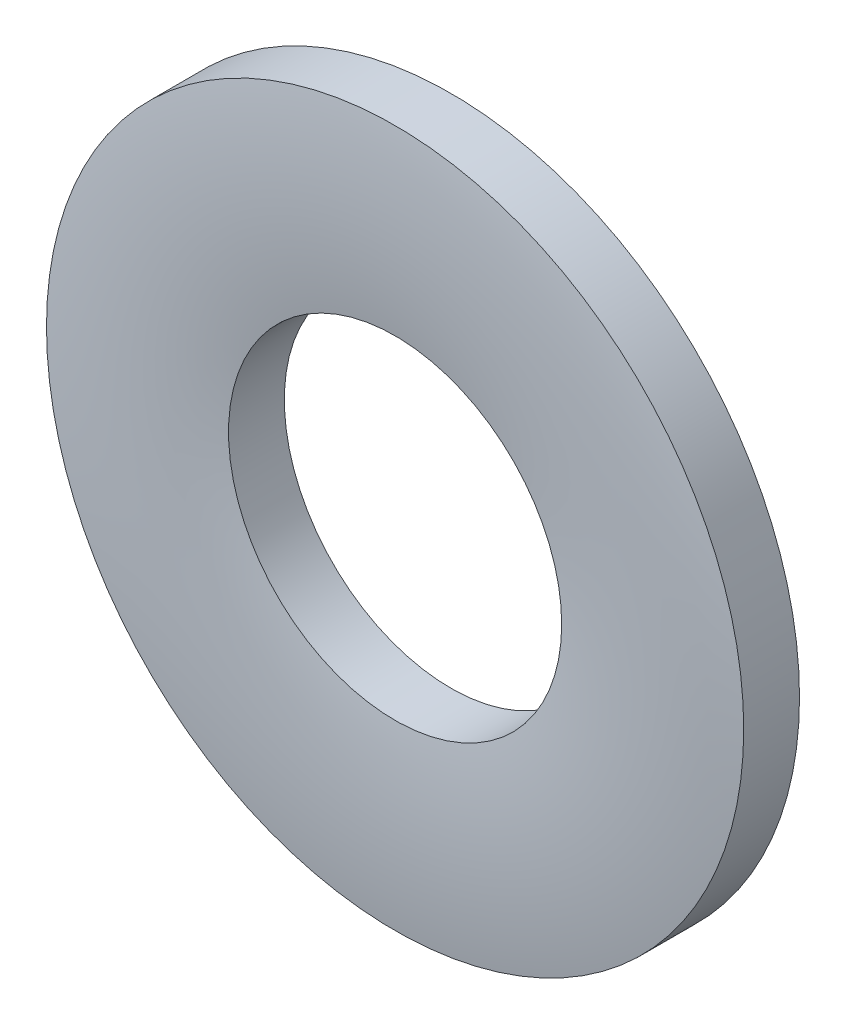
from build123d import *


with BuildPart() as part:
    # Sketch3 → Revolve1 (revolve)
    with BuildSketch(Plane(origin=(0, 0, 0), x_dir=(0, 0, -1), z_dir=(1, 0, 0))):
        with BuildLine():
            Line((0.4, 4.5), (-0.32, 4.5))
            ThreePointArc((-0.32, 4.5), (-0.4, 3.325), (-0.32, 2.15))
            Line((-0.32, 2.15), (0.4, 2.15))
            Line((0.4, 2.15), (0.4, 4.5))
        make_face()
    revolve(axis=Axis((0, 0, 0.4), (0, 0, -1)))


solid = part.part
